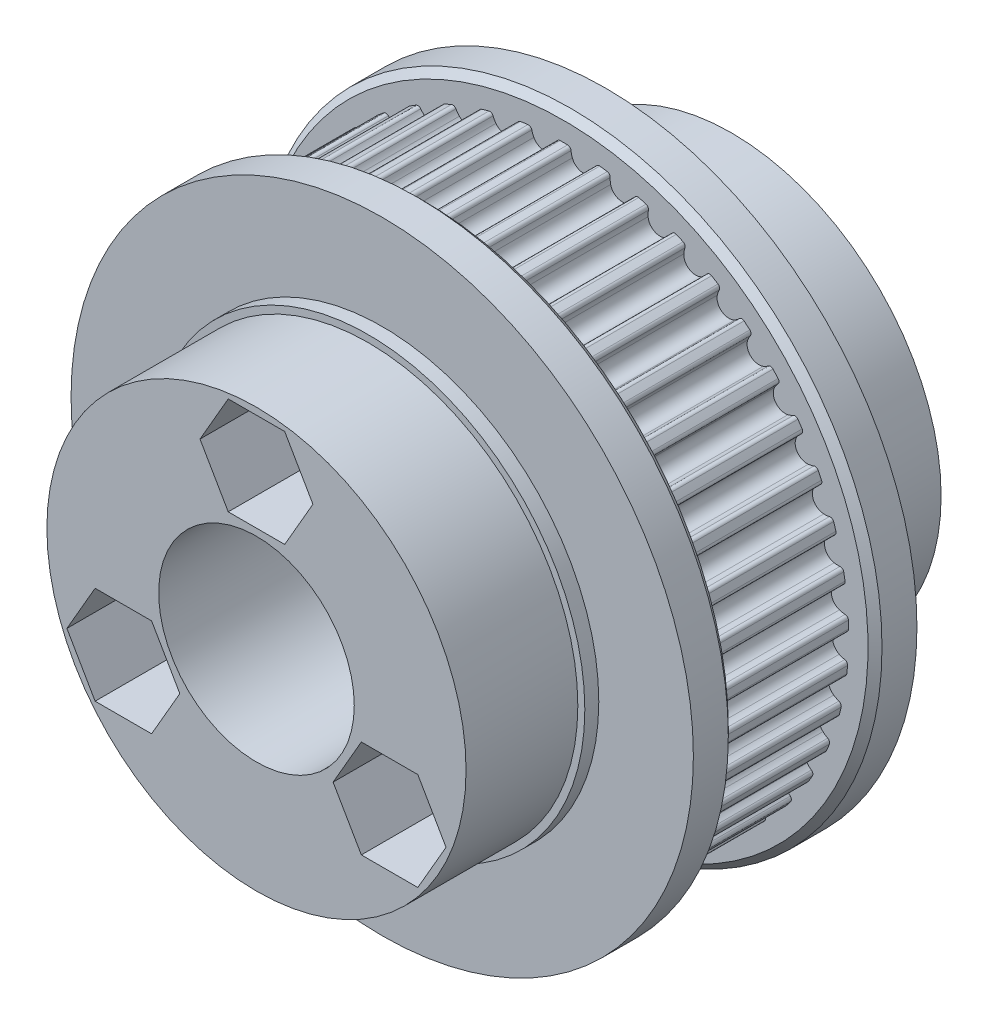
from build123d import *

# Parameters (mm, degrees)
SKETCH_1_R                       = 20.769720073
EXTRUDE_1_DEPTH                  = 5
CUT_EXTRUDE_1_DEPTH              = 32.028415104
PATTERN_CIRCULAR_1_COUNT         = 45
PATTERN_CIRCULAR_1_COPY_1_DEPTH  = 32.028415104
PATTERN_CIRCULAR_1_COPY_2_DEPTH  = 32.028415104
PATTERN_CIRCULAR_1_COPY_3_DEPTH  = 32.028415104
PATTERN_CIRCULAR_1_COPY_4_DEPTH  = 32.028415104
PATTERN_CIRCULAR_1_COPY_5_DEPTH  = 32.028415104
PATTERN_CIRCULAR_1_COPY_6_DEPTH  = 32.028415104
PATTERN_CIRCULAR_1_COPY_7_DEPTH  = 32.028415104
PATTERN_CIRCULAR_1_COPY_8_DEPTH  = 32.028415104
PATTERN_CIRCULAR_1_COPY_9_DEPTH  = 32.028415104
PATTERN_CIRCULAR_1_COPY_10_DEPTH = 32.028415104
PATTERN_CIRCULAR_1_COPY_11_DEPTH = 32.028415104
PATTERN_CIRCULAR_1_COPY_12_DEPTH = 32.028415104
PATTERN_CIRCULAR_1_COPY_13_DEPTH = 32.028415104
PATTERN_CIRCULAR_1_COPY_14_DEPTH = 32.028415104
PATTERN_CIRCULAR_1_COPY_15_DEPTH = 32.028415104
PATTERN_CIRCULAR_1_COPY_16_DEPTH = 32.028415104
PATTERN_CIRCULAR_1_COPY_17_DEPTH = 32.028415104
PATTERN_CIRCULAR_1_COPY_18_DEPTH = 32.028415104
PATTERN_CIRCULAR_1_COPY_19_DEPTH = 32.028415104
PATTERN_CIRCULAR_1_COPY_20_DEPTH = 32.028415104
PATTERN_CIRCULAR_1_COPY_21_DEPTH = 32.028415104
PATTERN_CIRCULAR_1_COPY_22_DEPTH = 32.028415104
PATTERN_CIRCULAR_1_COPY_23_DEPTH = 32.028415104
PATTERN_CIRCULAR_1_COPY_24_DEPTH = 32.028415104
PATTERN_CIRCULAR_1_COPY_25_DEPTH = 32.028415104
PATTERN_CIRCULAR_1_COPY_26_DEPTH = 32.028415104
PATTERN_CIRCULAR_1_COPY_27_DEPTH = 32.028415104
PATTERN_CIRCULAR_1_COPY_28_DEPTH = 32.028415104
PATTERN_CIRCULAR_1_COPY_29_DEPTH = 32.028415104
PATTERN_CIRCULAR_1_COPY_30_DEPTH = 32.028415104
PATTERN_CIRCULAR_1_COPY_31_DEPTH = 32.028415104
PATTERN_CIRCULAR_1_COPY_32_DEPTH = 32.028415104
PATTERN_CIRCULAR_1_COPY_33_DEPTH = 32.028415104
PATTERN_CIRCULAR_1_COPY_34_DEPTH = 32.028415104
PATTERN_CIRCULAR_1_COPY_35_DEPTH = 32.028415104
PATTERN_CIRCULAR_1_COPY_36_DEPTH = 32.028415104
PATTERN_CIRCULAR_1_COPY_37_DEPTH = 32.028415104
PATTERN_CIRCULAR_1_COPY_38_DEPTH = 32.028415104
PATTERN_CIRCULAR_1_COPY_39_DEPTH = 32.028415104
PATTERN_CIRCULAR_1_COPY_40_DEPTH = 32.028415104
PATTERN_CIRCULAR_1_COPY_41_DEPTH = 32.028415104
PATTERN_CIRCULAR_1_COPY_42_DEPTH = 32.028415104
PATTERN_CIRCULAR_1_COPY_43_DEPTH = 32.028415104
PATTERN_CIRCULAR_1_COPY_44_DEPTH = 32.028415104
SKETCH_3_R                       = 22.269720073
EXTRUDE_2_DEPTH                  = 3
CHAMFER_1_SIZE                   = 0.5
SKETCH_7_R                       = 22.269720073
EXTRUDE_3_DEPTH                  = 3
CHAMFER_2_SIZE                   = 0.5
SKETCH_8_R                       = 15.5
EXTRUDE_4_DEPTH                  = 1
SKETCH_9_R                       = 15
EXTRUDE_5_DEPTH                  = 8
SKETCH_4_R                       = 7
CUT_EXTRUDE_2_DEPTH              = 36.789395976
CUT_EXTRUDE_2_DEPTH_BACK         = 36.789395976
HOLE_WIZARD_M4_1_D               = 4.8
CUT_EXTRUDE_4_DEPTH              = 6.4
PATTERN_CIRCULAR_3_COUNT         = 3


with BuildPart() as part:
    # ｽｹｯﾁ1 → ﾎﾞｽ - 押し出し1 (new, symmetric)
    with BuildSketch(Plane.XY):
        Circle(SKETCH_1_R)
    extrude(amount=EXTRUDE_1_DEPTH, both=True)

    # ｽｹｯﾁ2 → ｶｯﾄ - 押し出し1 (cut, through all)
    with BuildSketch(Plane.XY.offset(5)):
        with BuildLine():
            Line((0, 20.769720073), (0, 20.388720073))
            ThreePointArc((0, 20.388720073), (0.134629216, 20.388275582), (0.269252561, 20.386942127))
            ThreePointArc((0.269252561, 20.386942127), (0.436454679, 20.319798607), (0.515090947, 20.157684024))
            ThreePointArc((0.515090947, 20.157684024), (0.546429865, 19.952254747), (0.605495363, 19.753019753))
            ThreePointArc((0.605495363, 19.753019753), (0.89304001, 19.368993677), (1.342722836, 19.201831159))
            Line((1.342722836, 19.201831159), (1.448822433, 20.719126079))
            ThreePointArc((1.448822433, 20.719126079), (0.724852777, 20.757067721), (0, 20.769720073))
        make_face()
    cut_extrude_1 = extrude(amount=-CUT_EXTRUDE_1_DEPTH, mode=Mode.SUBTRACT)

    # ﾐﾗｰ1: ｶｯﾄ - 押し出し1 across plane
    add(cut_extrude_1.mirror(Plane(origin=(0, 0, 0), x_dir=(0, 0, 1), z_dir=(1, 0, 0))), mode=Mode.SUBTRACT)

    # 円形ﾊﾟﾀｰﾝ1: ｶｯﾄ - 押し出し1 ×45 about axis
    pattern_circular_1_axis = Axis((0, 0, 0), (0, 0, 1))
    for i in range(1, PATTERN_CIRCULAR_1_COUNT):
        add(cut_extrude_1.rotate(pattern_circular_1_axis, i * 360 / PATTERN_CIRCULAR_1_COUNT), mode=Mode.SUBTRACT)

    # 円形ﾊﾟﾀｰﾝ1 copy 1 sketch → 円形ﾊﾟﾀｰﾝ1 copy 1 (cut, through all)
    with BuildSketch(Plane(origin=(0, 0, 5), x_dir=(-0.9902680687415704, -0.13917310096006544, 0), z_dir=(0, 0, 1))):
        with BuildLine():
            Line((0, -20.769720073), (0, -20.388720073))
            ThreePointArc((0, -20.388720073), (0.134629216, -20.388275582), (0.269252561, -20.386942127))
            ThreePointArc((0.269252561, -20.386942127), (0.436454679, -20.319798607), (0.515090947, -20.157684024))
            ThreePointArc((0.515090947, -20.157684024), (0.546429865, -19.952254747), (0.605495363, -19.753019753))
            ThreePointArc((0.605495363, -19.753019753), (0.89304001, -19.368993677), (1.342722836, -19.201831159))
            Line((1.342722836, -19.201831159), (1.448822433, -20.719126079))
            ThreePointArc((1.448822433, -20.719126079), (0.724852777, -20.757067721), (0, -20.769720073))
        make_face()
    extrude(amount=-PATTERN_CIRCULAR_1_COPY_1_DEPTH, mode=Mode.SUBTRACT)

    # 円形ﾊﾟﾀｰﾝ1 copy 2 sketch → 円形ﾊﾟﾀｰﾝ1 copy 2 (cut, through all)
    with BuildSketch(Plane(origin=(0, 0, 5), x_dir=(-0.9612616959383189, -0.27563735581699916, 0), z_dir=(0, 0, 1))):
        with BuildLine():
            Line((0, -20.769720073), (0, -20.388720073))
            ThreePointArc((0, -20.388720073), (0.134629216, -20.388275582), (0.269252561, -20.386942127))
            ThreePointArc((0.269252561, -20.386942127), (0.436454679, -20.319798607), (0.515090947, -20.157684024))
            ThreePointArc((0.515090947, -20.157684024), (0.546429865, -19.952254747), (0.605495363, -19.753019753))
            ThreePointArc((0.605495363, -19.753019753), (0.89304001, -19.368993677), (1.342722836, -19.201831159))
            Line((1.342722836, -19.201831159), (1.448822433, -20.719126079))
            ThreePointArc((1.448822433, -20.719126079), (0.724852777, -20.757067721), (0, -20.769720073))
        make_face()
    extrude(amount=-PATTERN_CIRCULAR_1_COPY_2_DEPTH, mode=Mode.SUBTRACT)

    # 円形ﾊﾟﾀｰﾝ1 copy 3 sketch → 円形ﾊﾟﾀｰﾝ1 copy 3 (cut, through all)
    with BuildSketch(Plane(origin=(0, 0, 5), x_dir=(-0.9135454576426009, -0.4067366430758002, 0), z_dir=(0, 0, 1))):
        with BuildLine():
            Line((0, -20.769720073), (0, -20.388720073))
            ThreePointArc((0, -20.388720073), (0.134629216, -20.388275582), (0.269252561, -20.386942127))
            ThreePointArc((0.269252561, -20.386942127), (0.436454679, -20.319798607), (0.515090947, -20.157684024))
            ThreePointArc((0.515090947, -20.157684024), (0.546429865, -19.952254747), (0.605495363, -19.753019753))
            ThreePointArc((0.605495363, -19.753019753), (0.89304001, -19.368993677), (1.342722836, -19.201831159))
            Line((1.342722836, -19.201831159), (1.448822433, -20.719126079))
            ThreePointArc((1.448822433, -20.719126079), (0.724852777, -20.757067721), (0, -20.769720073))
        make_face()
    extrude(amount=-PATTERN_CIRCULAR_1_COPY_3_DEPTH, mode=Mode.SUBTRACT)

    # 円形ﾊﾟﾀｰﾝ1 copy 4 sketch → 円形ﾊﾟﾀｰﾝ1 copy 4 (cut, through all)
    with BuildSketch(Plane(origin=(0, 0, 5), x_dir=(-0.848048096156426, -0.5299192642332049, 0), z_dir=(0, 0, 1))):
        with BuildLine():
            Line((0, -20.769720073), (0, -20.388720073))
            ThreePointArc((0, -20.388720073), (0.134629216, -20.388275582), (0.269252561, -20.386942127))
            ThreePointArc((0.269252561, -20.386942127), (0.436454679, -20.319798607), (0.515090947, -20.157684024))
            ThreePointArc((0.515090947, -20.157684024), (0.546429865, -19.952254747), (0.605495363, -19.753019753))
            ThreePointArc((0.605495363, -19.753019753), (0.89304001, -19.368993677), (1.342722836, -19.201831159))
            Line((1.342722836, -19.201831159), (1.448822433, -20.719126079))
            ThreePointArc((1.448822433, -20.719126079), (0.724852777, -20.757067721), (0, -20.769720073))
        make_face()
    extrude(amount=-PATTERN_CIRCULAR_1_COPY_4_DEPTH, mode=Mode.SUBTRACT)

    # 円形ﾊﾟﾀｰﾝ1 copy 5 sketch → 円形ﾊﾟﾀｰﾝ1 copy 5 (cut, through all)
    with BuildSketch(Plane(origin=(0, 0, 5), x_dir=(-0.766044443118978, -0.6427876096865393, 0), z_dir=(0, 0, 1))):
        with BuildLine():
            Line((0, -20.769720073), (0, -20.388720073))
            ThreePointArc((0, -20.388720073), (0.134629216, -20.388275582), (0.269252561, -20.386942127))
            ThreePointArc((0.269252561, -20.386942127), (0.436454679, -20.319798607), (0.515090947, -20.157684024))
            ThreePointArc((0.515090947, -20.157684024), (0.546429865, -19.952254747), (0.605495363, -19.753019753))
            ThreePointArc((0.605495363, -19.753019753), (0.89304001, -19.368993677), (1.342722836, -19.201831159))
            Line((1.342722836, -19.201831159), (1.448822433, -20.719126079))
            ThreePointArc((1.448822433, -20.719126079), (0.724852777, -20.757067721), (0, -20.769720073))
        make_face()
    extrude(amount=-PATTERN_CIRCULAR_1_COPY_5_DEPTH, mode=Mode.SUBTRACT)

    # 円形ﾊﾟﾀｰﾝ1 copy 6 sketch → 円形ﾊﾟﾀｰﾝ1 copy 6 (cut, through all)
    with BuildSketch(Plane(origin=(0, 0, 5), x_dir=(-0.6691306063588582, -0.7431448254773942, 0), z_dir=(0, 0, 1))):
        with BuildLine():
            Line((0, -20.769720073), (0, -20.388720073))
            ThreePointArc((0, -20.388720073), (0.134629216, -20.388275582), (0.269252561, -20.386942127))
            ThreePointArc((0.269252561, -20.386942127), (0.436454679, -20.319798607), (0.515090947, -20.157684024))
            ThreePointArc((0.515090947, -20.157684024), (0.546429865, -19.952254747), (0.605495363, -19.753019753))
            ThreePointArc((0.605495363, -19.753019753), (0.89304001, -19.368993677), (1.342722836, -19.201831159))
            Line((1.342722836, -19.201831159), (1.448822433, -20.719126079))
            ThreePointArc((1.448822433, -20.719126079), (0.724852777, -20.757067721), (0, -20.769720073))
        make_face()
    extrude(amount=-PATTERN_CIRCULAR_1_COPY_6_DEPTH, mode=Mode.SUBTRACT)

    # 円形ﾊﾟﾀｰﾝ1 copy 7 sketch → 円形ﾊﾟﾀｰﾝ1 copy 7 (cut, through all)
    with BuildSketch(Plane(origin=(0, 0, 5), x_dir=(-0.5591929034707468, -0.8290375725550417, 0), z_dir=(0, 0, 1))):
        with BuildLine():
            Line((0, -20.769720073), (0, -20.388720073))
            ThreePointArc((0, -20.388720073), (0.134629216, -20.388275582), (0.269252561, -20.386942127))
            ThreePointArc((0.269252561, -20.386942127), (0.436454679, -20.319798607), (0.515090947, -20.157684024))
            ThreePointArc((0.515090947, -20.157684024), (0.546429865, -19.952254747), (0.605495363, -19.753019753))
            ThreePointArc((0.605495363, -19.753019753), (0.89304001, -19.368993677), (1.342722836, -19.201831159))
            Line((1.342722836, -19.201831159), (1.448822433, -20.719126079))
            ThreePointArc((1.448822433, -20.719126079), (0.724852777, -20.757067721), (0, -20.769720073))
        make_face()
    extrude(amount=-PATTERN_CIRCULAR_1_COPY_7_DEPTH, mode=Mode.SUBTRACT)

    # 円形ﾊﾟﾀｰﾝ1 copy 8 sketch → 円形ﾊﾟﾀｰﾝ1 copy 8 (cut, through all)
    with BuildSketch(Plane(origin=(0, 0, 5), x_dir=(-0.43837114678907746, -0.898794046299167, 0), z_dir=(0, 0, 1))):
        with BuildLine():
            Line((0, -20.769720073), (0, -20.388720073))
            ThreePointArc((0, -20.388720073), (0.134629216, -20.388275582), (0.269252561, -20.386942127))
            ThreePointArc((0.269252561, -20.386942127), (0.436454679, -20.319798607), (0.515090947, -20.157684024))
            ThreePointArc((0.515090947, -20.157684024), (0.546429865, -19.952254747), (0.605495363, -19.753019753))
            ThreePointArc((0.605495363, -19.753019753), (0.89304001, -19.368993677), (1.342722836, -19.201831159))
            Line((1.342722836, -19.201831159), (1.448822433, -20.719126079))
            ThreePointArc((1.448822433, -20.719126079), (0.724852777, -20.757067721), (0, -20.769720073))
        make_face()
    extrude(amount=-PATTERN_CIRCULAR_1_COPY_8_DEPTH, mode=Mode.SUBTRACT)

    # 円形ﾊﾟﾀｰﾝ1 copy 9 sketch → 円形ﾊﾟﾀｰﾝ1 copy 9 (cut, through all)
    with BuildSketch(Plane(origin=(0, 0, 5), x_dir=(-0.30901699437494745, -0.9510565162951535, 0), z_dir=(0, 0, 1))):
        with BuildLine():
            Line((0, -20.769720073), (0, -20.388720073))
            ThreePointArc((0, -20.388720073), (0.134629216, -20.388275582), (0.269252561, -20.386942127))
            ThreePointArc((0.269252561, -20.386942127), (0.436454679, -20.319798607), (0.515090947, -20.157684024))
            ThreePointArc((0.515090947, -20.157684024), (0.546429865, -19.952254747), (0.605495363, -19.753019753))
            ThreePointArc((0.605495363, -19.753019753), (0.89304001, -19.368993677), (1.342722836, -19.201831159))
            Line((1.342722836, -19.201831159), (1.448822433, -20.719126079))
            ThreePointArc((1.448822433, -20.719126079), (0.724852777, -20.757067721), (0, -20.769720073))
        make_face()
    extrude(amount=-PATTERN_CIRCULAR_1_COPY_9_DEPTH, mode=Mode.SUBTRACT)

    # 円形ﾊﾟﾀｰﾝ1 copy 10 sketch → 円形ﾊﾟﾀｰﾝ1 copy 10 (cut, through all)
    with BuildSketch(Plane(origin=(0, 0, 5), x_dir=(-0.17364817766693041, -0.984807753012208, 0), z_dir=(0, 0, 1))):
        with BuildLine():
            Line((0, -20.769720073), (0, -20.388720073))
            ThreePointArc((0, -20.388720073), (0.134629216, -20.388275582), (0.269252561, -20.386942127))
            ThreePointArc((0.269252561, -20.386942127), (0.436454679, -20.319798607), (0.515090947, -20.157684024))
            ThreePointArc((0.515090947, -20.157684024), (0.546429865, -19.952254747), (0.605495363, -19.753019753))
            ThreePointArc((0.605495363, -19.753019753), (0.89304001, -19.368993677), (1.342722836, -19.201831159))
            Line((1.342722836, -19.201831159), (1.448822433, -20.719126079))
            ThreePointArc((1.448822433, -20.719126079), (0.724852777, -20.757067721), (0, -20.769720073))
        make_face()
    extrude(amount=-PATTERN_CIRCULAR_1_COPY_10_DEPTH, mode=Mode.SUBTRACT)

    # 円形ﾊﾟﾀｰﾝ1 copy 11 sketch → 円形ﾊﾟﾀｰﾝ1 copy 11 (cut, through all)
    with BuildSketch(Plane(origin=(0, 0, 5), x_dir=(-0.03489949670250108, -0.9993908270190958, 0), z_dir=(0, 0, 1))):
        with BuildLine():
            Line((0, -20.769720073), (0, -20.388720073))
            ThreePointArc((0, -20.388720073), (0.134629216, -20.388275582), (0.269252561, -20.386942127))
            ThreePointArc((0.269252561, -20.386942127), (0.436454679, -20.319798607), (0.515090947, -20.157684024))
            ThreePointArc((0.515090947, -20.157684024), (0.546429865, -19.952254747), (0.605495363, -19.753019753))
            ThreePointArc((0.605495363, -19.753019753), (0.89304001, -19.368993677), (1.342722836, -19.201831159))
            Line((1.342722836, -19.201831159), (1.448822433, -20.719126079))
            ThreePointArc((1.448822433, -20.719126079), (0.724852777, -20.757067721), (0, -20.769720073))
        make_face()
    extrude(amount=-PATTERN_CIRCULAR_1_COPY_11_DEPTH, mode=Mode.SUBTRACT)

    # 円形ﾊﾟﾀｰﾝ1 copy 12 sketch → 円形ﾊﾟﾀｰﾝ1 copy 12 (cut, through all)
    with BuildSketch(Plane(origin=(0, 0, 5), x_dir=(0.10452846326765355, -0.9945218953682733, 0), z_dir=(0, 0, 1))):
        with BuildLine():
            Line((0, -20.769720073), (0, -20.388720073))
            ThreePointArc((0, -20.388720073), (0.134629216, -20.388275582), (0.269252561, -20.386942127))
            ThreePointArc((0.269252561, -20.386942127), (0.436454679, -20.319798607), (0.515090947, -20.157684024))
            ThreePointArc((0.515090947, -20.157684024), (0.546429865, -19.952254747), (0.605495363, -19.753019753))
            ThreePointArc((0.605495363, -19.753019753), (0.89304001, -19.368993677), (1.342722836, -19.201831159))
            Line((1.342722836, -19.201831159), (1.448822433, -20.719126079))
            ThreePointArc((1.448822433, -20.719126079), (0.724852777, -20.757067721), (0, -20.769720073))
        make_face()
    extrude(amount=-PATTERN_CIRCULAR_1_COPY_12_DEPTH, mode=Mode.SUBTRACT)

    # 円形ﾊﾟﾀｰﾝ1 copy 13 sketch → 円形ﾊﾟﾀｰﾝ1 copy 13 (cut, through all)
    with BuildSketch(Plane(origin=(0, 0, 5), x_dir=(0.24192189559966779, -0.9702957262759965, 0), z_dir=(0, 0, 1))):
        with BuildLine():
            Line((0, -20.769720073), (0, -20.388720073))
            ThreePointArc((0, -20.388720073), (0.134629216, -20.388275582), (0.269252561, -20.386942127))
            ThreePointArc((0.269252561, -20.386942127), (0.436454679, -20.319798607), (0.515090947, -20.157684024))
            ThreePointArc((0.515090947, -20.157684024), (0.546429865, -19.952254747), (0.605495363, -19.753019753))
            ThreePointArc((0.605495363, -19.753019753), (0.89304001, -19.368993677), (1.342722836, -19.201831159))
            Line((1.342722836, -19.201831159), (1.448822433, -20.719126079))
            ThreePointArc((1.448822433, -20.719126079), (0.724852777, -20.757067721), (0, -20.769720073))
        make_face()
    extrude(amount=-PATTERN_CIRCULAR_1_COPY_13_DEPTH, mode=Mode.SUBTRACT)

    # 円形ﾊﾟﾀｰﾝ1 copy 14 sketch → 円形ﾊﾟﾀｰﾝ1 copy 14 (cut, through all)
    with BuildSketch(Plane(origin=(0, 0, 5), x_dir=(0.37460659341591207, -0.9271838545667874, 0), z_dir=(0, 0, 1))):
        with BuildLine():
            Line((0, -20.769720073), (0, -20.388720073))
            ThreePointArc((0, -20.388720073), (0.134629216, -20.388275582), (0.269252561, -20.386942127))
            ThreePointArc((0.269252561, -20.386942127), (0.436454679, -20.319798607), (0.515090947, -20.157684024))
            ThreePointArc((0.515090947, -20.157684024), (0.546429865, -19.952254747), (0.605495363, -19.753019753))
            ThreePointArc((0.605495363, -19.753019753), (0.89304001, -19.368993677), (1.342722836, -19.201831159))
            Line((1.342722836, -19.201831159), (1.448822433, -20.719126079))
            ThreePointArc((1.448822433, -20.719126079), (0.724852777, -20.757067721), (0, -20.769720073))
        make_face()
    extrude(amount=-PATTERN_CIRCULAR_1_COPY_14_DEPTH, mode=Mode.SUBTRACT)

    # 円形ﾊﾟﾀｰﾝ1 copy 15 sketch → 円形ﾊﾟﾀｰﾝ1 copy 15 (cut, through all)
    with BuildSketch(Plane(origin=(0, 0, 5), x_dir=(0.4999999999999998, -0.8660254037844387, 0), z_dir=(0, 0, 1))):
        with BuildLine():
            Line((0, -20.769720073), (0, -20.388720073))
            ThreePointArc((0, -20.388720073), (0.134629216, -20.388275582), (0.269252561, -20.386942127))
            ThreePointArc((0.269252561, -20.386942127), (0.436454679, -20.319798607), (0.515090947, -20.157684024))
            ThreePointArc((0.515090947, -20.157684024), (0.546429865, -19.952254747), (0.605495363, -19.753019753))
            ThreePointArc((0.605495363, -19.753019753), (0.89304001, -19.368993677), (1.342722836, -19.201831159))
            Line((1.342722836, -19.201831159), (1.448822433, -20.719126079))
            ThreePointArc((1.448822433, -20.719126079), (0.724852777, -20.757067721), (0, -20.769720073))
        make_face()
    extrude(amount=-PATTERN_CIRCULAR_1_COPY_15_DEPTH, mode=Mode.SUBTRACT)

    # 円形ﾊﾟﾀｰﾝ1 copy 16 sketch → 円形ﾊﾟﾀｰﾝ1 copy 16 (cut, through all)
    with BuildSketch(Plane(origin=(0, 0, 5), x_dir=(0.6156614753256583, -0.788010753606722, 0), z_dir=(0, 0, 1))):
        with BuildLine():
            Line((0, -20.769720073), (0, -20.388720073))
            ThreePointArc((0, -20.388720073), (0.134629216, -20.388275582), (0.269252561, -20.386942127))
            ThreePointArc((0.269252561, -20.386942127), (0.436454679, -20.319798607), (0.515090947, -20.157684024))
            ThreePointArc((0.515090947, -20.157684024), (0.546429865, -19.952254747), (0.605495363, -19.753019753))
            ThreePointArc((0.605495363, -19.753019753), (0.89304001, -19.368993677), (1.342722836, -19.201831159))
            Line((1.342722836, -19.201831159), (1.448822433, -20.719126079))
            ThreePointArc((1.448822433, -20.719126079), (0.724852777, -20.757067721), (0, -20.769720073))
        make_face()
    extrude(amount=-PATTERN_CIRCULAR_1_COPY_16_DEPTH, mode=Mode.SUBTRACT)

    # 円形ﾊﾟﾀｰﾝ1 copy 17 sketch → 円形ﾊﾟﾀｰﾝ1 copy 17 (cut, through all)
    with BuildSketch(Plane(origin=(0, 0, 5), x_dir=(0.7193398003386512, -0.6946583704589971, 0), z_dir=(0, 0, 1))):
        with BuildLine():
            Line((0, -20.769720073), (0, -20.388720073))
            ThreePointArc((0, -20.388720073), (0.134629216, -20.388275582), (0.269252561, -20.386942127))
            ThreePointArc((0.269252561, -20.386942127), (0.436454679, -20.319798607), (0.515090947, -20.157684024))
            ThreePointArc((0.515090947, -20.157684024), (0.546429865, -19.952254747), (0.605495363, -19.753019753))
            ThreePointArc((0.605495363, -19.753019753), (0.89304001, -19.368993677), (1.342722836, -19.201831159))
            Line((1.342722836, -19.201831159), (1.448822433, -20.719126079))
            ThreePointArc((1.448822433, -20.719126079), (0.724852777, -20.757067721), (0, -20.769720073))
        make_face()
    extrude(amount=-PATTERN_CIRCULAR_1_COPY_17_DEPTH, mode=Mode.SUBTRACT)

    # 円形ﾊﾟﾀｰﾝ1 copy 18 sketch → 円形ﾊﾟﾀｰﾝ1 copy 18 (cut, through all)
    with BuildSketch(Plane(origin=(0, 0, 5), x_dir=(0.8090169943749473, -0.5877852522924732, 0), z_dir=(0, 0, 1))):
        with BuildLine():
            Line((0, -20.769720073), (0, -20.388720073))
            ThreePointArc((0, -20.388720073), (0.134629216, -20.388275582), (0.269252561, -20.386942127))
            ThreePointArc((0.269252561, -20.386942127), (0.436454679, -20.319798607), (0.515090947, -20.157684024))
            ThreePointArc((0.515090947, -20.157684024), (0.546429865, -19.952254747), (0.605495363, -19.753019753))
            ThreePointArc((0.605495363, -19.753019753), (0.89304001, -19.368993677), (1.342722836, -19.201831159))
            Line((1.342722836, -19.201831159), (1.448822433, -20.719126079))
            ThreePointArc((1.448822433, -20.719126079), (0.724852777, -20.757067721), (0, -20.769720073))
        make_face()
    extrude(amount=-PATTERN_CIRCULAR_1_COPY_18_DEPTH, mode=Mode.SUBTRACT)

    # 円形ﾊﾟﾀｰﾝ1 copy 19 sketch → 円形ﾊﾟﾀｰﾝ1 copy 19 (cut, through all)
    with BuildSketch(Plane(origin=(0, 0, 5), x_dir=(0.882947592858927, -0.4694715627858907, 0), z_dir=(0, 0, 1))):
        with BuildLine():
            Line((0, -20.769720073), (0, -20.388720073))
            ThreePointArc((0, -20.388720073), (0.134629216, -20.388275582), (0.269252561, -20.386942127))
            ThreePointArc((0.269252561, -20.386942127), (0.436454679, -20.319798607), (0.515090947, -20.157684024))
            ThreePointArc((0.515090947, -20.157684024), (0.546429865, -19.952254747), (0.605495363, -19.753019753))
            ThreePointArc((0.605495363, -19.753019753), (0.89304001, -19.368993677), (1.342722836, -19.201831159))
            Line((1.342722836, -19.201831159), (1.448822433, -20.719126079))
            ThreePointArc((1.448822433, -20.719126079), (0.724852777, -20.757067721), (0, -20.769720073))
        make_face()
    extrude(amount=-PATTERN_CIRCULAR_1_COPY_19_DEPTH, mode=Mode.SUBTRACT)

    # 円形ﾊﾟﾀｰﾝ1 copy 20 sketch → 円形ﾊﾟﾀｰﾝ1 copy 20 (cut, through all)
    with BuildSketch(Plane(origin=(0, 0, 5), x_dir=(0.9396926207859083, -0.3420201433256689, 0), z_dir=(0, 0, 1))):
        with BuildLine():
            Line((0, -20.769720073), (0, -20.388720073))
            ThreePointArc((0, -20.388720073), (0.134629216, -20.388275582), (0.269252561, -20.386942127))
            ThreePointArc((0.269252561, -20.386942127), (0.436454679, -20.319798607), (0.515090947, -20.157684024))
            ThreePointArc((0.515090947, -20.157684024), (0.546429865, -19.952254747), (0.605495363, -19.753019753))
            ThreePointArc((0.605495363, -19.753019753), (0.89304001, -19.368993677), (1.342722836, -19.201831159))
            Line((1.342722836, -19.201831159), (1.448822433, -20.719126079))
            ThreePointArc((1.448822433, -20.719126079), (0.724852777, -20.757067721), (0, -20.769720073))
        make_face()
    extrude(amount=-PATTERN_CIRCULAR_1_COPY_20_DEPTH, mode=Mode.SUBTRACT)

    # 円形ﾊﾟﾀｰﾝ1 copy 21 sketch → 円形ﾊﾟﾀｰﾝ1 copy 21 (cut, through all)
    with BuildSketch(Plane(origin=(0, 0, 5), x_dir=(0.9781476007338057, -0.20791169081775931, 0), z_dir=(0, 0, 1))):
        with BuildLine():
            Line((0, -20.769720073), (0, -20.388720073))
            ThreePointArc((0, -20.388720073), (0.134629216, -20.388275582), (0.269252561, -20.386942127))
            ThreePointArc((0.269252561, -20.386942127), (0.436454679, -20.319798607), (0.515090947, -20.157684024))
            ThreePointArc((0.515090947, -20.157684024), (0.546429865, -19.952254747), (0.605495363, -19.753019753))
            ThreePointArc((0.605495363, -19.753019753), (0.89304001, -19.368993677), (1.342722836, -19.201831159))
            Line((1.342722836, -19.201831159), (1.448822433, -20.719126079))
            ThreePointArc((1.448822433, -20.719126079), (0.724852777, -20.757067721), (0, -20.769720073))
        make_face()
    extrude(amount=-PATTERN_CIRCULAR_1_COPY_21_DEPTH, mode=Mode.SUBTRACT)

    # 円形ﾊﾟﾀｰﾝ1 copy 22 sketch → 円形ﾊﾟﾀｰﾝ1 copy 22 (cut, through all)
    with BuildSketch(Plane(origin=(0, 0, 5), x_dir=(0.9975640502598242, -0.06975647374412552, 0), z_dir=(0, 0, 1))):
        with BuildLine():
            Line((0, -20.769720073), (0, -20.388720073))
            ThreePointArc((0, -20.388720073), (0.134629216, -20.388275582), (0.269252561, -20.386942127))
            ThreePointArc((0.269252561, -20.386942127), (0.436454679, -20.319798607), (0.515090947, -20.157684024))
            ThreePointArc((0.515090947, -20.157684024), (0.546429865, -19.952254747), (0.605495363, -19.753019753))
            ThreePointArc((0.605495363, -19.753019753), (0.89304001, -19.368993677), (1.342722836, -19.201831159))
            Line((1.342722836, -19.201831159), (1.448822433, -20.719126079))
            ThreePointArc((1.448822433, -20.719126079), (0.724852777, -20.757067721), (0, -20.769720073))
        make_face()
    extrude(amount=-PATTERN_CIRCULAR_1_COPY_22_DEPTH, mode=Mode.SUBTRACT)

    # 円形ﾊﾟﾀｰﾝ1 copy 23 sketch → 円形ﾊﾟﾀｰﾝ1 copy 23 (cut, through all)
    with BuildSketch(Plane(origin=(0, 0, 5), x_dir=(0.9975640502598242, 0.06975647374412527, 0), z_dir=(0, 0, 1))):
        with BuildLine():
            Line((0, -20.769720073), (0, -20.388720073))
            ThreePointArc((0, -20.388720073), (0.134629216, -20.388275582), (0.269252561, -20.386942127))
            ThreePointArc((0.269252561, -20.386942127), (0.436454679, -20.319798607), (0.515090947, -20.157684024))
            ThreePointArc((0.515090947, -20.157684024), (0.546429865, -19.952254747), (0.605495363, -19.753019753))
            ThreePointArc((0.605495363, -19.753019753), (0.89304001, -19.368993677), (1.342722836, -19.201831159))
            Line((1.342722836, -19.201831159), (1.448822433, -20.719126079))
            ThreePointArc((1.448822433, -20.719126079), (0.724852777, -20.757067721), (0, -20.769720073))
        make_face()
    extrude(amount=-PATTERN_CIRCULAR_1_COPY_23_DEPTH, mode=Mode.SUBTRACT)

    # 円形ﾊﾟﾀｰﾝ1 copy 24 sketch → 円形ﾊﾟﾀｰﾝ1 copy 24 (cut, through all)
    with BuildSketch(Plane(origin=(0, 0, 5), x_dir=(0.9781476007338056, 0.2079116908177595, 0), z_dir=(0, 0, 1))):
        with BuildLine():
            Line((0, -20.769720073), (0, -20.388720073))
            ThreePointArc((0, -20.388720073), (0.134629216, -20.388275582), (0.269252561, -20.386942127))
            ThreePointArc((0.269252561, -20.386942127), (0.436454679, -20.319798607), (0.515090947, -20.157684024))
            ThreePointArc((0.515090947, -20.157684024), (0.546429865, -19.952254747), (0.605495363, -19.753019753))
            ThreePointArc((0.605495363, -19.753019753), (0.89304001, -19.368993677), (1.342722836, -19.201831159))
            Line((1.342722836, -19.201831159), (1.448822433, -20.719126079))
            ThreePointArc((1.448822433, -20.719126079), (0.724852777, -20.757067721), (0, -20.769720073))
        make_face()
    extrude(amount=-PATTERN_CIRCULAR_1_COPY_24_DEPTH, mode=Mode.SUBTRACT)

    # 円形ﾊﾟﾀｰﾝ1 copy 25 sketch → 円形ﾊﾟﾀｰﾝ1 copy 25 (cut, through all)
    with BuildSketch(Plane(origin=(0, 0, 5), x_dir=(0.9396926207859084, 0.34202014332566866, 0), z_dir=(0, 0, 1))):
        with BuildLine():
            Line((0, -20.769720073), (0, -20.388720073))
            ThreePointArc((0, -20.388720073), (0.134629216, -20.388275582), (0.269252561, -20.386942127))
            ThreePointArc((0.269252561, -20.386942127), (0.436454679, -20.319798607), (0.515090947, -20.157684024))
            ThreePointArc((0.515090947, -20.157684024), (0.546429865, -19.952254747), (0.605495363, -19.753019753))
            ThreePointArc((0.605495363, -19.753019753), (0.89304001, -19.368993677), (1.342722836, -19.201831159))
            Line((1.342722836, -19.201831159), (1.448822433, -20.719126079))
            ThreePointArc((1.448822433, -20.719126079), (0.724852777, -20.757067721), (0, -20.769720073))
        make_face()
    extrude(amount=-PATTERN_CIRCULAR_1_COPY_25_DEPTH, mode=Mode.SUBTRACT)

    # 円形ﾊﾟﾀｰﾝ1 copy 26 sketch → 円形ﾊﾟﾀｰﾝ1 copy 26 (cut, through all)
    with BuildSketch(Plane(origin=(0, 0, 5), x_dir=(0.8829475928589269, 0.46947156278589086, 0), z_dir=(0, 0, 1))):
        with BuildLine():
            Line((0, -20.769720073), (0, -20.388720073))
            ThreePointArc((0, -20.388720073), (0.134629216, -20.388275582), (0.269252561, -20.386942127))
            ThreePointArc((0.269252561, -20.386942127), (0.436454679, -20.319798607), (0.515090947, -20.157684024))
            ThreePointArc((0.515090947, -20.157684024), (0.546429865, -19.952254747), (0.605495363, -19.753019753))
            ThreePointArc((0.605495363, -19.753019753), (0.89304001, -19.368993677), (1.342722836, -19.201831159))
            Line((1.342722836, -19.201831159), (1.448822433, -20.719126079))
            ThreePointArc((1.448822433, -20.719126079), (0.724852777, -20.757067721), (0, -20.769720073))
        make_face()
    extrude(amount=-PATTERN_CIRCULAR_1_COPY_26_DEPTH, mode=Mode.SUBTRACT)

    # 円形ﾊﾟﾀｰﾝ1 copy 27 sketch → 円形ﾊﾟﾀｰﾝ1 copy 27 (cut, through all)
    with BuildSketch(Plane(origin=(0, 0, 5), x_dir=(0.8090169943749476, 0.587785252292473, 0), z_dir=(0, 0, 1))):
        with BuildLine():
            Line((0, -20.769720073), (0, -20.388720073))
            ThreePointArc((0, -20.388720073), (0.134629216, -20.388275582), (0.269252561, -20.386942127))
            ThreePointArc((0.269252561, -20.386942127), (0.436454679, -20.319798607), (0.515090947, -20.157684024))
            ThreePointArc((0.515090947, -20.157684024), (0.546429865, -19.952254747), (0.605495363, -19.753019753))
            ThreePointArc((0.605495363, -19.753019753), (0.89304001, -19.368993677), (1.342722836, -19.201831159))
            Line((1.342722836, -19.201831159), (1.448822433, -20.719126079))
            ThreePointArc((1.448822433, -20.719126079), (0.724852777, -20.757067721), (0, -20.769720073))
        make_face()
    extrude(amount=-PATTERN_CIRCULAR_1_COPY_27_DEPTH, mode=Mode.SUBTRACT)

    # 円形ﾊﾟﾀｰﾝ1 copy 28 sketch → 円形ﾊﾟﾀｰﾝ1 copy 28 (cut, through all)
    with BuildSketch(Plane(origin=(0, 0, 5), x_dir=(0.7193398003386511, 0.6946583704589974, 0), z_dir=(0, 0, 1))):
        with BuildLine():
            Line((0, -20.769720073), (0, -20.388720073))
            ThreePointArc((0, -20.388720073), (0.134629216, -20.388275582), (0.269252561, -20.386942127))
            ThreePointArc((0.269252561, -20.386942127), (0.436454679, -20.319798607), (0.515090947, -20.157684024))
            ThreePointArc((0.515090947, -20.157684024), (0.546429865, -19.952254747), (0.605495363, -19.753019753))
            ThreePointArc((0.605495363, -19.753019753), (0.89304001, -19.368993677), (1.342722836, -19.201831159))
            Line((1.342722836, -19.201831159), (1.448822433, -20.719126079))
            ThreePointArc((1.448822433, -20.719126079), (0.724852777, -20.757067721), (0, -20.769720073))
        make_face()
    extrude(amount=-PATTERN_CIRCULAR_1_COPY_28_DEPTH, mode=Mode.SUBTRACT)

    # 円形ﾊﾟﾀｰﾝ1 copy 29 sketch → 円形ﾊﾟﾀｰﾝ1 copy 29 (cut, through all)
    with BuildSketch(Plane(origin=(0, 0, 5), x_dir=(0.6156614753256581, 0.7880107536067221, 0), z_dir=(0, 0, 1))):
        with BuildLine():
            Line((0, -20.769720073), (0, -20.388720073))
            ThreePointArc((0, -20.388720073), (0.134629216, -20.388275582), (0.269252561, -20.386942127))
            ThreePointArc((0.269252561, -20.386942127), (0.436454679, -20.319798607), (0.515090947, -20.157684024))
            ThreePointArc((0.515090947, -20.157684024), (0.546429865, -19.952254747), (0.605495363, -19.753019753))
            ThreePointArc((0.605495363, -19.753019753), (0.89304001, -19.368993677), (1.342722836, -19.201831159))
            Line((1.342722836, -19.201831159), (1.448822433, -20.719126079))
            ThreePointArc((1.448822433, -20.719126079), (0.724852777, -20.757067721), (0, -20.769720073))
        make_face()
    extrude(amount=-PATTERN_CIRCULAR_1_COPY_29_DEPTH, mode=Mode.SUBTRACT)

    # 円形ﾊﾟﾀｰﾝ1 copy 30 sketch → 円形ﾊﾟﾀｰﾝ1 copy 30 (cut, through all)
    with BuildSketch(Plane(origin=(0, 0, 5), x_dir=(0.5000000000000004, 0.8660254037844384, 0), z_dir=(0, 0, 1))):
        with BuildLine():
            Line((0, -20.769720073), (0, -20.388720073))
            ThreePointArc((0, -20.388720073), (0.134629216, -20.388275582), (0.269252561, -20.386942127))
            ThreePointArc((0.269252561, -20.386942127), (0.436454679, -20.319798607), (0.515090947, -20.157684024))
            ThreePointArc((0.515090947, -20.157684024), (0.546429865, -19.952254747), (0.605495363, -19.753019753))
            ThreePointArc((0.605495363, -19.753019753), (0.89304001, -19.368993677), (1.342722836, -19.201831159))
            Line((1.342722836, -19.201831159), (1.448822433, -20.719126079))
            ThreePointArc((1.448822433, -20.719126079), (0.724852777, -20.757067721), (0, -20.769720073))
        make_face()
    extrude(amount=-PATTERN_CIRCULAR_1_COPY_30_DEPTH, mode=Mode.SUBTRACT)

    # 円形ﾊﾟﾀｰﾝ1 copy 31 sketch → 円形ﾊﾟﾀｰﾝ1 copy 31 (cut, through all)
    with BuildSketch(Plane(origin=(0, 0, 5), x_dir=(0.3746065934159123, 0.9271838545667873, 0), z_dir=(0, 0, 1))):
        with BuildLine():
            Line((0, -20.769720073), (0, -20.388720073))
            ThreePointArc((0, -20.388720073), (0.134629216, -20.388275582), (0.269252561, -20.386942127))
            ThreePointArc((0.269252561, -20.386942127), (0.436454679, -20.319798607), (0.515090947, -20.157684024))
            ThreePointArc((0.515090947, -20.157684024), (0.546429865, -19.952254747), (0.605495363, -19.753019753))
            ThreePointArc((0.605495363, -19.753019753), (0.89304001, -19.368993677), (1.342722836, -19.201831159))
            Line((1.342722836, -19.201831159), (1.448822433, -20.719126079))
            ThreePointArc((1.448822433, -20.719126079), (0.724852777, -20.757067721), (0, -20.769720073))
        make_face()
    extrude(amount=-PATTERN_CIRCULAR_1_COPY_31_DEPTH, mode=Mode.SUBTRACT)

    # 円形ﾊﾟﾀｰﾝ1 copy 32 sketch → 円形ﾊﾟﾀｰﾝ1 copy 32 (cut, through all)
    with BuildSketch(Plane(origin=(0, 0, 5), x_dir=(0.24192189559966779, 0.9702957262759965, 0), z_dir=(0, 0, 1))):
        with BuildLine():
            Line((0, -20.769720073), (0, -20.388720073))
            ThreePointArc((0, -20.388720073), (0.134629216, -20.388275582), (0.269252561, -20.386942127))
            ThreePointArc((0.269252561, -20.386942127), (0.436454679, -20.319798607), (0.515090947, -20.157684024))
            ThreePointArc((0.515090947, -20.157684024), (0.546429865, -19.952254747), (0.605495363, -19.753019753))
            ThreePointArc((0.605495363, -19.753019753), (0.89304001, -19.368993677), (1.342722836, -19.201831159))
            Line((1.342722836, -19.201831159), (1.448822433, -20.719126079))
            ThreePointArc((1.448822433, -20.719126079), (0.724852777, -20.757067721), (0, -20.769720073))
        make_face()
    extrude(amount=-PATTERN_CIRCULAR_1_COPY_32_DEPTH, mode=Mode.SUBTRACT)

    # 円形ﾊﾟﾀｰﾝ1 copy 33 sketch → 円形ﾊﾟﾀｰﾝ1 copy 33 (cut, through all)
    with BuildSketch(Plane(origin=(0, 0, 5), x_dir=(0.10452846326765336, 0.9945218953682734, 0), z_dir=(0, 0, 1))):
        with BuildLine():
            Line((0, -20.769720073), (0, -20.388720073))
            ThreePointArc((0, -20.388720073), (0.134629216, -20.388275582), (0.269252561, -20.386942127))
            ThreePointArc((0.269252561, -20.386942127), (0.436454679, -20.319798607), (0.515090947, -20.157684024))
            ThreePointArc((0.515090947, -20.157684024), (0.546429865, -19.952254747), (0.605495363, -19.753019753))
            ThreePointArc((0.605495363, -19.753019753), (0.89304001, -19.368993677), (1.342722836, -19.201831159))
            Line((1.342722836, -19.201831159), (1.448822433, -20.719126079))
            ThreePointArc((1.448822433, -20.719126079), (0.724852777, -20.757067721), (0, -20.769720073))
        make_face()
    extrude(amount=-PATTERN_CIRCULAR_1_COPY_33_DEPTH, mode=Mode.SUBTRACT)

    # 円形ﾊﾟﾀｰﾝ1 copy 34 sketch → 円形ﾊﾟﾀｰﾝ1 copy 34 (cut, through all)
    with BuildSketch(Plane(origin=(0, 0, 5), x_dir=(-0.03489949670250128, 0.9993908270190958, 0), z_dir=(0, 0, 1))):
        with BuildLine():
            Line((0, -20.769720073), (0, -20.388720073))
            ThreePointArc((0, -20.388720073), (0.134629216, -20.388275582), (0.269252561, -20.386942127))
            ThreePointArc((0.269252561, -20.386942127), (0.436454679, -20.319798607), (0.515090947, -20.157684024))
            ThreePointArc((0.515090947, -20.157684024), (0.546429865, -19.952254747), (0.605495363, -19.753019753))
            ThreePointArc((0.605495363, -19.753019753), (0.89304001, -19.368993677), (1.342722836, -19.201831159))
            Line((1.342722836, -19.201831159), (1.448822433, -20.719126079))
            ThreePointArc((1.448822433, -20.719126079), (0.724852777, -20.757067721), (0, -20.769720073))
        make_face()
    extrude(amount=-PATTERN_CIRCULAR_1_COPY_34_DEPTH, mode=Mode.SUBTRACT)

    # 円形ﾊﾟﾀｰﾝ1 copy 35 sketch → 円形ﾊﾟﾀｰﾝ1 copy 35 (cut, through all)
    with BuildSketch(Plane(origin=(0, 0, 5), x_dir=(-0.17364817766692997, 0.9848077530122081, 0), z_dir=(0, 0, 1))):
        with BuildLine():
            Line((0, -20.769720073), (0, -20.388720073))
            ThreePointArc((0, -20.388720073), (0.134629216, -20.388275582), (0.269252561, -20.386942127))
            ThreePointArc((0.269252561, -20.386942127), (0.436454679, -20.319798607), (0.515090947, -20.157684024))
            ThreePointArc((0.515090947, -20.157684024), (0.546429865, -19.952254747), (0.605495363, -19.753019753))
            ThreePointArc((0.605495363, -19.753019753), (0.89304001, -19.368993677), (1.342722836, -19.201831159))
            Line((1.342722836, -19.201831159), (1.448822433, -20.719126079))
            ThreePointArc((1.448822433, -20.719126079), (0.724852777, -20.757067721), (0, -20.769720073))
        make_face()
    extrude(amount=-PATTERN_CIRCULAR_1_COPY_35_DEPTH, mode=Mode.SUBTRACT)

    # 円形ﾊﾟﾀｰﾝ1 copy 36 sketch → 円形ﾊﾟﾀｰﾝ1 copy 36 (cut, through all)
    with BuildSketch(Plane(origin=(0, 0, 5), x_dir=(-0.30901699437494723, 0.9510565162951536, 0), z_dir=(0, 0, 1))):
        with BuildLine():
            Line((0, -20.769720073), (0, -20.388720073))
            ThreePointArc((0, -20.388720073), (0.134629216, -20.388275582), (0.269252561, -20.386942127))
            ThreePointArc((0.269252561, -20.386942127), (0.436454679, -20.319798607), (0.515090947, -20.157684024))
            ThreePointArc((0.515090947, -20.157684024), (0.546429865, -19.952254747), (0.605495363, -19.753019753))
            ThreePointArc((0.605495363, -19.753019753), (0.89304001, -19.368993677), (1.342722836, -19.201831159))
            Line((1.342722836, -19.201831159), (1.448822433, -20.719126079))
            ThreePointArc((1.448822433, -20.719126079), (0.724852777, -20.757067721), (0, -20.769720073))
        make_face()
    extrude(amount=-PATTERN_CIRCULAR_1_COPY_36_DEPTH, mode=Mode.SUBTRACT)

    # 円形ﾊﾟﾀｰﾝ1 copy 37 sketch → 円形ﾊﾟﾀｰﾝ1 copy 37 (cut, through all)
    with BuildSketch(Plane(origin=(0, 0, 5), x_dir=(-0.4383711467890774, 0.898794046299167, 0), z_dir=(0, 0, 1))):
        with BuildLine():
            Line((0, -20.769720073), (0, -20.388720073))
            ThreePointArc((0, -20.388720073), (0.134629216, -20.388275582), (0.269252561, -20.386942127))
            ThreePointArc((0.269252561, -20.386942127), (0.436454679, -20.319798607), (0.515090947, -20.157684024))
            ThreePointArc((0.515090947, -20.157684024), (0.546429865, -19.952254747), (0.605495363, -19.753019753))
            ThreePointArc((0.605495363, -19.753019753), (0.89304001, -19.368993677), (1.342722836, -19.201831159))
            Line((1.342722836, -19.201831159), (1.448822433, -20.719126079))
            ThreePointArc((1.448822433, -20.719126079), (0.724852777, -20.757067721), (0, -20.769720073))
        make_face()
    extrude(amount=-PATTERN_CIRCULAR_1_COPY_37_DEPTH, mode=Mode.SUBTRACT)

    # 円形ﾊﾟﾀｰﾝ1 copy 38 sketch → 円形ﾊﾟﾀｰﾝ1 copy 38 (cut, through all)
    with BuildSketch(Plane(origin=(0, 0, 5), x_dir=(-0.559192903470747, 0.8290375725550416, 0), z_dir=(0, 0, 1))):
        with BuildLine():
            Line((0, -20.769720073), (0, -20.388720073))
            ThreePointArc((0, -20.388720073), (0.134629216, -20.388275582), (0.269252561, -20.386942127))
            ThreePointArc((0.269252561, -20.386942127), (0.436454679, -20.319798607), (0.515090947, -20.157684024))
            ThreePointArc((0.515090947, -20.157684024), (0.546429865, -19.952254747), (0.605495363, -19.753019753))
            ThreePointArc((0.605495363, -19.753019753), (0.89304001, -19.368993677), (1.342722836, -19.201831159))
            Line((1.342722836, -19.201831159), (1.448822433, -20.719126079))
            ThreePointArc((1.448822433, -20.719126079), (0.724852777, -20.757067721), (0, -20.769720073))
        make_face()
    extrude(amount=-PATTERN_CIRCULAR_1_COPY_38_DEPTH, mode=Mode.SUBTRACT)

    # 円形ﾊﾟﾀｰﾝ1 copy 39 sketch → 円形ﾊﾟﾀｰﾝ1 copy 39 (cut, through all)
    with BuildSketch(Plane(origin=(0, 0, 5), x_dir=(-0.6691306063588578, 0.7431448254773946, 0), z_dir=(0, 0, 1))):
        with BuildLine():
            Line((0, -20.769720073), (0, -20.388720073))
            ThreePointArc((0, -20.388720073), (0.134629216, -20.388275582), (0.269252561, -20.386942127))
            ThreePointArc((0.269252561, -20.386942127), (0.436454679, -20.319798607), (0.515090947, -20.157684024))
            ThreePointArc((0.515090947, -20.157684024), (0.546429865, -19.952254747), (0.605495363, -19.753019753))
            ThreePointArc((0.605495363, -19.753019753), (0.89304001, -19.368993677), (1.342722836, -19.201831159))
            Line((1.342722836, -19.201831159), (1.448822433, -20.719126079))
            ThreePointArc((1.448822433, -20.719126079), (0.724852777, -20.757067721), (0, -20.769720073))
        make_face()
    extrude(amount=-PATTERN_CIRCULAR_1_COPY_39_DEPTH, mode=Mode.SUBTRACT)

    # 円形ﾊﾟﾀｰﾝ1 copy 40 sketch → 円形ﾊﾟﾀｰﾝ1 copy 40 (cut, through all)
    with BuildSketch(Plane(origin=(0, 0, 5), x_dir=(-0.7660444431189778, 0.6427876096865396, 0), z_dir=(0, 0, 1))):
        with BuildLine():
            Line((0, -20.769720073), (0, -20.388720073))
            ThreePointArc((0, -20.388720073), (0.134629216, -20.388275582), (0.269252561, -20.386942127))
            ThreePointArc((0.269252561, -20.386942127), (0.436454679, -20.319798607), (0.515090947, -20.157684024))
            ThreePointArc((0.515090947, -20.157684024), (0.546429865, -19.952254747), (0.605495363, -19.753019753))
            ThreePointArc((0.605495363, -19.753019753), (0.89304001, -19.368993677), (1.342722836, -19.201831159))
            Line((1.342722836, -19.201831159), (1.448822433, -20.719126079))
            ThreePointArc((1.448822433, -20.719126079), (0.724852777, -20.757067721), (0, -20.769720073))
        make_face()
    extrude(amount=-PATTERN_CIRCULAR_1_COPY_40_DEPTH, mode=Mode.SUBTRACT)

    # 円形ﾊﾟﾀｰﾝ1 copy 41 sketch → 円形ﾊﾟﾀｰﾝ1 copy 41 (cut, through all)
    with BuildSketch(Plane(origin=(0, 0, 5), x_dir=(-0.848048096156426, 0.529919264233205, 0), z_dir=(0, 0, 1))):
        with BuildLine():
            Line((0, -20.769720073), (0, -20.388720073))
            ThreePointArc((0, -20.388720073), (0.134629216, -20.388275582), (0.269252561, -20.386942127))
            ThreePointArc((0.269252561, -20.386942127), (0.436454679, -20.319798607), (0.515090947, -20.157684024))
            ThreePointArc((0.515090947, -20.157684024), (0.546429865, -19.952254747), (0.605495363, -19.753019753))
            ThreePointArc((0.605495363, -19.753019753), (0.89304001, -19.368993677), (1.342722836, -19.201831159))
            Line((1.342722836, -19.201831159), (1.448822433, -20.719126079))
            ThreePointArc((1.448822433, -20.719126079), (0.724852777, -20.757067721), (0, -20.769720073))
        make_face()
    extrude(amount=-PATTERN_CIRCULAR_1_COPY_41_DEPTH, mode=Mode.SUBTRACT)

    # 円形ﾊﾟﾀｰﾝ1 copy 42 sketch → 円形ﾊﾟﾀｰﾝ1 copy 42 (cut, through all)
    with BuildSketch(Plane(origin=(0, 0, 5), x_dir=(-0.913545457642601, 0.40673664307580015, 0), z_dir=(0, 0, 1))):
        with BuildLine():
            Line((0, -20.769720073), (0, -20.388720073))
            ThreePointArc((0, -20.388720073), (0.134629216, -20.388275582), (0.269252561, -20.386942127))
            ThreePointArc((0.269252561, -20.386942127), (0.436454679, -20.319798607), (0.515090947, -20.157684024))
            ThreePointArc((0.515090947, -20.157684024), (0.546429865, -19.952254747), (0.605495363, -19.753019753))
            ThreePointArc((0.605495363, -19.753019753), (0.89304001, -19.368993677), (1.342722836, -19.201831159))
            Line((1.342722836, -19.201831159), (1.448822433, -20.719126079))
            ThreePointArc((1.448822433, -20.719126079), (0.724852777, -20.757067721), (0, -20.769720073))
        make_face()
    extrude(amount=-PATTERN_CIRCULAR_1_COPY_42_DEPTH, mode=Mode.SUBTRACT)

    # 円形ﾊﾟﾀｰﾝ1 copy 43 sketch → 円形ﾊﾟﾀｰﾝ1 copy 43 (cut, through all)
    with BuildSketch(Plane(origin=(0, 0, 5), x_dir=(-0.9612616959383189, 0.27563735581699894, 0), z_dir=(0, 0, 1))):
        with BuildLine():
            Line((0, -20.769720073), (0, -20.388720073))
            ThreePointArc((0, -20.388720073), (0.134629216, -20.388275582), (0.269252561, -20.386942127))
            ThreePointArc((0.269252561, -20.386942127), (0.436454679, -20.319798607), (0.515090947, -20.157684024))
            ThreePointArc((0.515090947, -20.157684024), (0.546429865, -19.952254747), (0.605495363, -19.753019753))
            ThreePointArc((0.605495363, -19.753019753), (0.89304001, -19.368993677), (1.342722836, -19.201831159))
            Line((1.342722836, -19.201831159), (1.448822433, -20.719126079))
            ThreePointArc((1.448822433, -20.719126079), (0.724852777, -20.757067721), (0, -20.769720073))
        make_face()
    extrude(amount=-PATTERN_CIRCULAR_1_COPY_43_DEPTH, mode=Mode.SUBTRACT)

    # 円形ﾊﾟﾀｰﾝ1 copy 44 sketch → 円形ﾊﾟﾀｰﾝ1 copy 44 (cut, through all)
    with BuildSketch(Plane(origin=(0, 0, 5), x_dir=(-0.9902680687415703, 0.13917310096006588, 0), z_dir=(0, 0, 1))):
        with BuildLine():
            Line((0, -20.769720073), (0, -20.388720073))
            ThreePointArc((0, -20.388720073), (0.134629216, -20.388275582), (0.269252561, -20.386942127))
            ThreePointArc((0.269252561, -20.386942127), (0.436454679, -20.319798607), (0.515090947, -20.157684024))
            ThreePointArc((0.515090947, -20.157684024), (0.546429865, -19.952254747), (0.605495363, -19.753019753))
            ThreePointArc((0.605495363, -19.753019753), (0.89304001, -19.368993677), (1.342722836, -19.201831159))
            Line((1.342722836, -19.201831159), (1.448822433, -20.719126079))
            ThreePointArc((1.448822433, -20.719126079), (0.724852777, -20.757067721), (0, -20.769720073))
        make_face()
    extrude(amount=-PATTERN_CIRCULAR_1_COPY_44_DEPTH, mode=Mode.SUBTRACT)

    # ｽｹｯﾁ3 → ﾎﾞｽ - 押し出し2 (add)
    with BuildSketch(Plane.XY.offset(5)):
        Circle(SKETCH_3_R)
    extrude(amount=EXTRUDE_2_DEPTH)

    # 面取り1
    chamfer_1_edges = [part.edges().sort_by_distance(p)[0] for p in [
        (-22.269720073, 0, 5),
    ]]
    chamfer(chamfer_1_edges, length=CHAMFER_1_SIZE)

    # ｽｹｯﾁ7 → ﾎﾞｽ - 押し出し3 (add)
    with BuildSketch(Plane(origin=(0, 0, -5), x_dir=(-1, 0, 0), z_dir=(0, 0, -1))):
        with Locations(Location((0, 0, 0), (0, 0, 180))):
            Circle(SKETCH_7_R)
    extrude(amount=EXTRUDE_3_DEPTH)

    # 面取り2
    chamfer_2_edges = [part.edges().sort_by_distance(p)[0] for p in [
        (-22.269720073, 0, -5),
    ]]
    chamfer(chamfer_2_edges, length=CHAMFER_2_SIZE)

    # ｽｹｯﾁ8 → ﾎﾞｽ - 押し出し4 (add)
    with BuildSketch(Plane(origin=(0, 0, -8), x_dir=(-1, 0, 0), z_dir=(0, 0, -1))):
        Circle(SKETCH_8_R)
    extrude_4 = extrude(amount=EXTRUDE_4_DEPTH)

    # ｽｹｯﾁ9 → ﾎﾞｽ - 押し出し5 (add)
    with BuildSketch(Plane(origin=(0, 0, -9), x_dir=(-1, 0, 0), z_dir=(0, 0, -1))):
        Circle(SKETCH_9_R)
    extrude_5 = extrude(amount=EXTRUDE_5_DEPTH)

    # ﾐﾗｰ2: ﾎﾞｽ - 押し出し4, ﾎﾞｽ - 押し出し5 across plane
    add(extrude_4.mirror(Plane.XY))
    add(extrude_5.mirror(Plane.XY))

    # ｽｹｯﾁ4 → ｶｯﾄ - 押し出し2 (cut, two sides)
    with BuildSketch(Plane.XY) as cut_extrude_2_sk:
        Circle(SKETCH_4_R)
    extrude(amount=CUT_EXTRUDE_2_DEPTH, mode=Mode.SUBTRACT)
    extrude(cut_extrude_2_sk.sketch, amount=-CUT_EXTRUDE_2_DEPTH_BACK, mode=Mode.SUBTRACT)

    # M4 すきま穴1 (through all)
    with Locations(Plane(origin=(0, 0, -17), x_dir=(-1, 0, 0), z_dir=(0, 0, -1))):
        with Locations((0, 11)):
            hole_wizard_m4_1 = Hole(HOLE_WIZARD_M4_1_D / 2)

    # ｽｹｯﾁ13 → ｶｯﾄ - 押し出し4 (cut)
    with BuildSketch(Plane.XY.offset(17)):
        Polygon((-2.020725942, 7.5), (2.020725942, 7.5), (4.041451884, 11), (2.020725942, 14.5), (-2.020725942, 14.5), (-4.041451884, 11), align=None)
    cut_extrude_4 = extrude(amount=-CUT_EXTRUDE_4_DEPTH, mode=Mode.SUBTRACT)

    # 円形ﾊﾟﾀｰﾝ3: M4 すきま穴1, ｶｯﾄ - 押し出し4 ×3 about axis
    pattern_circular_3_axis = Axis((0, 0, 0), (0, 0, 1))
    add([hole_wizard_m4_1.rotate(pattern_circular_3_axis, i * 360 / PATTERN_CIRCULAR_3_COUNT) for i in range(1, PATTERN_CIRCULAR_3_COUNT)], mode=Mode.SUBTRACT)
    add([cut_extrude_4.rotate(pattern_circular_3_axis, i * 360 / PATTERN_CIRCULAR_3_COUNT) for i in range(1, PATTERN_CIRCULAR_3_COUNT)], mode=Mode.SUBTRACT)


solid = part.part
